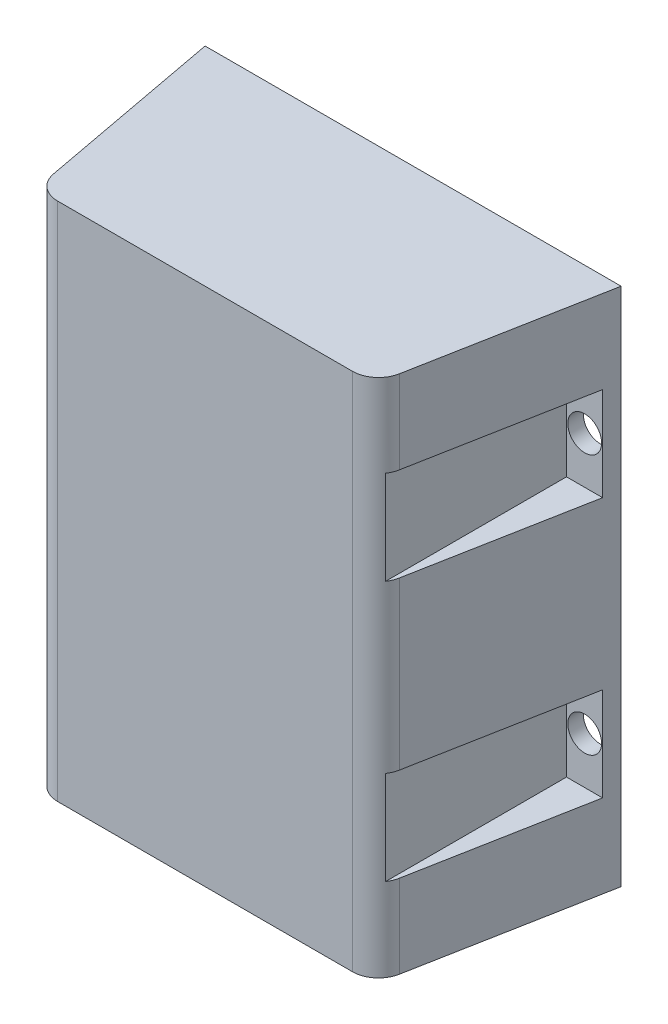
from build123d import *

# Parameters (mm, degrees)
SKETCH_1_W               = 80
SKETCH_1_H               = 100
EXTRUDE_1_DEPTH          = 40
SKETCH_2_OUTSIDE_W       = 108.832
SKETCH_2_OUTSIDE_H       = 68.832
CUT_EXTRUDE_1_DEPTH      = 1
CUT_EXTRUDE_1_DEPTH_BACK = 101
CUT_EXTRUDE_2_DEPTH      = 37
SKETCH_4_R               = 3.25
CUT_EXTRUDE_3_DEPTH      = 37
SKETCH_5_OUTSIDE_W       = 108.832
SKETCH_5_OUTSIDE_H       = 68.832
CUT_EXTRUDE_4_DEPTH      = 100


with BuildPart() as part:
    # 草图1 → 凸台-拉伸1 (new body)
    with BuildSketch(Plane.XY):
        Rectangle(SKETCH_1_W, SKETCH_1_H)
    extrude(amount=EXTRUDE_1_DEPTH)

    # 草图2 outside → 切除-拉伸1 (cut, two sides)
    with BuildSketch(Plane(origin=(0, -50, 0), x_dir=(-1, 0, 0), z_dir=(0, -1, 0))) as cut_extrude_1_sk:
        with Locations((0, -20)):
            Rectangle(SKETCH_2_OUTSIDE_W, SKETCH_2_OUTSIDE_H)
        Polygon((0, -40), (32.5, -40), (40, 0), (-40, 0), (-32.5, -40), align=None, mode=Mode.SUBTRACT)
    extrude(amount=CUT_EXTRUDE_1_DEPTH, mode=Mode.SUBTRACT)
    extrude(cut_extrude_1_sk.sketch, amount=-CUT_EXTRUDE_1_DEPTH_BACK, mode=Mode.SUBTRACT)

    # 草图3 → 切除-拉伸2 (cut)
    with BuildSketch(Plane.XY.offset(40)):
        Polygon((-40, -25), (-40, -34), (-32.5, -34), (-32.5, -16), (-40, -16), align=None)
        Polygon((-40, 16), (-40, 25), (-40, 34), (-32.5, 34), (-32.5, 16), align=None)
        Polygon((40, -16), (40, -25), (40, -34), (32.5, -34), (32.5, -16), align=None)
        Polygon((40, 25), (40, 34), (32.5, 34), (32.5, 16), (40, 16), align=None)
    extrude(amount=-CUT_EXTRUDE_2_DEPTH, mode=Mode.SUBTRACT)

    # 草图4 → 切除-拉伸3 (cut)
    with BuildSketch(Plane.XY.offset(3)):
        with Locations((-36, 25)):
            Circle(SKETCH_4_R)
        with Locations((36, 25)):
            Circle(SKETCH_4_R)
        with Locations((36, -25)):
            Circle(SKETCH_4_R)
        with Locations((-36, -25)):
            Circle(SKETCH_4_R)
    extrude(amount=-CUT_EXTRUDE_3_DEPTH, mode=Mode.SUBTRACT)

    # 草图5 outside → 切除-拉伸4 (cut)
    with BuildSketch(Plane.XZ.offset(50)):
        with Locations((0, 20)):
            Rectangle(SKETCH_5_OUTSIDE_W, SKETCH_5_OUTSIDE_H)
        with BuildLine():
            Line((-28.350368564, 40), (28.350368564, 40))
            ThreePointArc((28.350368564, 40), (31.543547749, 38.847545541), (33.264729498, 35.921442675))
            Line((33.264729498, 35.921442675), (40, 0))
            Line((40, 0), (-40, 0))
            Line((-40, 0), (-33.264729498, 35.921442675))
            ThreePointArc((-33.264729498, 35.921442675), (-31.543547749, 38.847545541), (-28.350368564, 40))
        make_face(mode=Mode.SUBTRACT)
    extrude(amount=-CUT_EXTRUDE_4_DEPTH, mode=Mode.SUBTRACT)


solid = part.part
